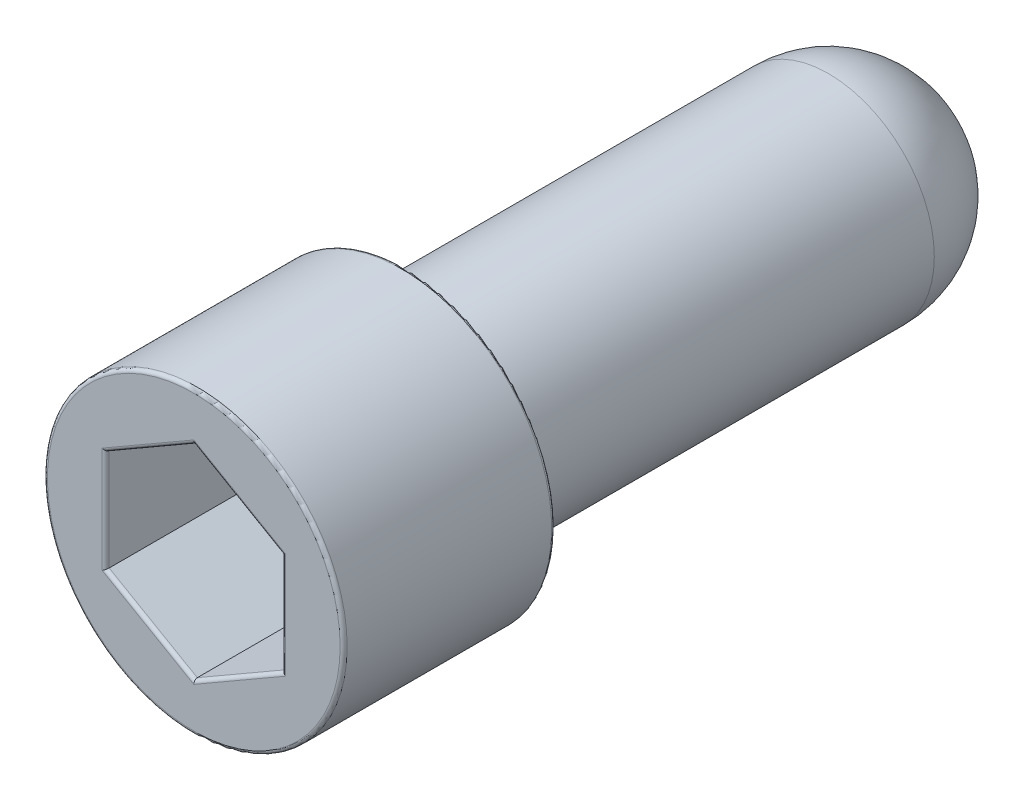
from build123d import *

# Parameters (mm, degrees)
SKETCH1_R           = 4.25
BOSS_EXTRUDE1_DEPTH = 6
CUT_EXTRUDE1_DEPTH  = 4
SKETCH3_R           = 3
BOSS_EXTRUDE2_DEPTH = 15
FILLET1_R           = 0.1
FILLET2_R           = 3


with BuildPart() as part:
    # Sketch1 → Boss-Extrude1 (new body)
    with BuildSketch(Plane.XY):
        Circle(SKETCH1_R)
    extrude(amount=BOSS_EXTRUDE1_DEPTH)

    # Sketch2 → Cut-Extrude1 (cut)
    with BuildSketch(Plane.XY.offset(6)):
        Polygon((0, 2.886751346), (-2.5, 1.443375673), (-2.5, -1.443375673), (0, -2.886751346), (2.5, -1.443375673), (2.5, 1.443375673), align=None)
    extrude(amount=-CUT_EXTRUDE1_DEPTH, mode=Mode.SUBTRACT)

    # Sketch3 → Boss-Extrude2 (add)
    with BuildSketch(Plane(origin=(0, 0, 0), x_dir=(-1, 0, 0), z_dir=(0, 0, -1))):
        Circle(SKETCH3_R)
    extrude(amount=BOSS_EXTRUDE2_DEPTH)

    # Fillet1
    fillet1_edges = [part.edges().sort_by_distance(p)[0] for p in [
        (1.25, 2.165063509, 6),
        (-1.25, 2.165063509, 6),
        (-2.5, 0, 6),
        (-1.25, -2.165063509, 6),
        (1.25, -2.165063509, 6),
        (2.5, 0, 6),
        (-4.25, 0, 0),
        (-4.25, 0, 6),
    ]]
    fillet(fillet1_edges, radius=FILLET1_R)

    # Fillet2
    fillet2_edges = [part.edges().sort_by_distance(p)[0] for p in [
        (3, 0, -15),
    ]]
    fillet(fillet2_edges, radius=FILLET2_R)


solid = part.part
